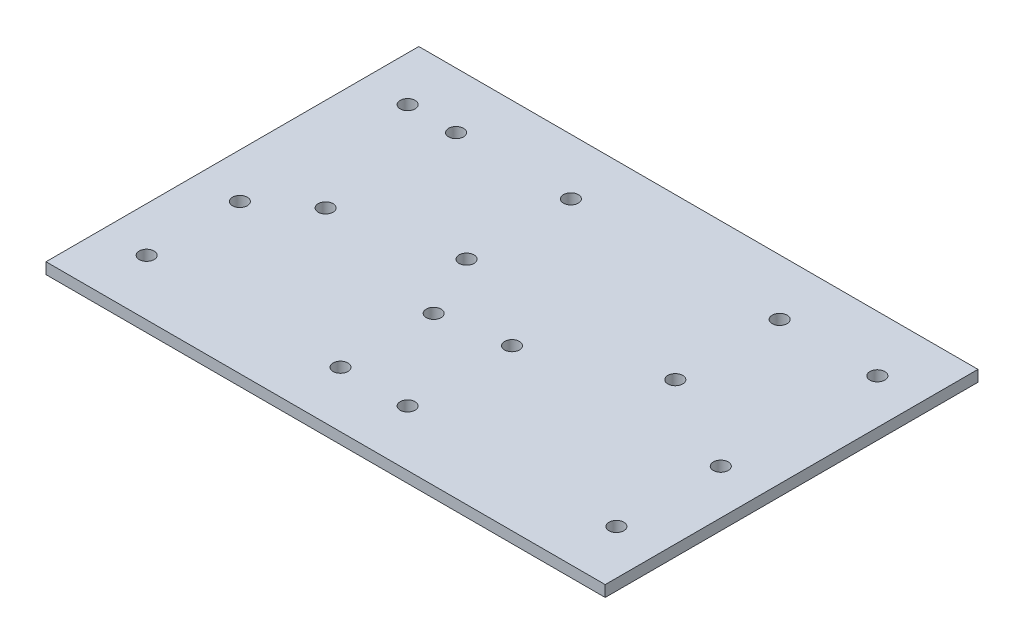
from build123d import *

# Parameters (mm, degrees)
SKETCH1_W           = 150
SKETCH1_H           = 100
SKETCH1_R           = 2
BOSS_EXTRUDE1_DEPTH = 3
SKETCH2_R           = 2
CUT_EXTRUDE1_DEPTH  = 3


with BuildPart() as part:
    # Sketch1 → Boss-Extrude1 (new body)
    with BuildSketch(Plane(origin=(0, 0, 0), x_dir=(1, 0, 0), z_dir=(0, 1, 0))):
        with Locations((63, -37.502720101)):
            Rectangle(SKETCH1_W, SKETCH1_H)
        with Locations((0, -2.502720101)):
            Circle(SKETCH1_R, mode=Mode.SUBTRACT)
        with Locations((126, -2.502720101)):
            Circle(SKETCH1_R, mode=Mode.SUBTRACT)
        with Locations((0, -72.502720101)):
            Circle(SKETCH1_R, mode=Mode.SUBTRACT)
        with Locations((126, -72.502720101)):
            Circle(SKETCH1_R, mode=Mode.SUBTRACT)
    extrude(amount=BOSS_EXTRUDE1_DEPTH)

    # Sketch2 → Cut-Extrude1 (cut)
    with BuildSketch(Plane(origin=(0, 3, 0), x_dir=(1, 0, 0), z_dir=(0, 1, 0))):
        with Locations((13, -2.502720101)):
            Circle(SKETCH2_R)
        with Locations((13, -37.502720101)):
            Circle(SKETCH2_R)
        with Locations((0, -47.502720101)):
            Circle(SKETCH2_R)
        with Locations((0, -72.502720101)):
            Circle(SKETCH2_R)
        with Locations((52, -47.502720101)):
            Circle(SKETCH2_R)
        with Locations((52, -72.502720101)):
            Circle(SKETCH2_R)
        with Locations((43.800232524, -2.502720101)):
            Circle(SKETCH2_R)
        with Locations((43.800232524, -30.502720101)):
            Circle(SKETCH2_R)
        with Locations((99.800232524, -2.502720101)):
            Circle(SKETCH2_R)
        with Locations((99.800232524, -30.502720101)):
            Circle(SKETCH2_R)
        with Locations((70, -44.502720101)):
            Circle(SKETCH2_R)
        with Locations((70, -72.502720101)):
            Circle(SKETCH2_R)
        with Locations((126, -44.502720101)):
            Circle(SKETCH2_R)
    extrude(amount=-CUT_EXTRUDE1_DEPTH, mode=Mode.SUBTRACT)


solid = part.part
